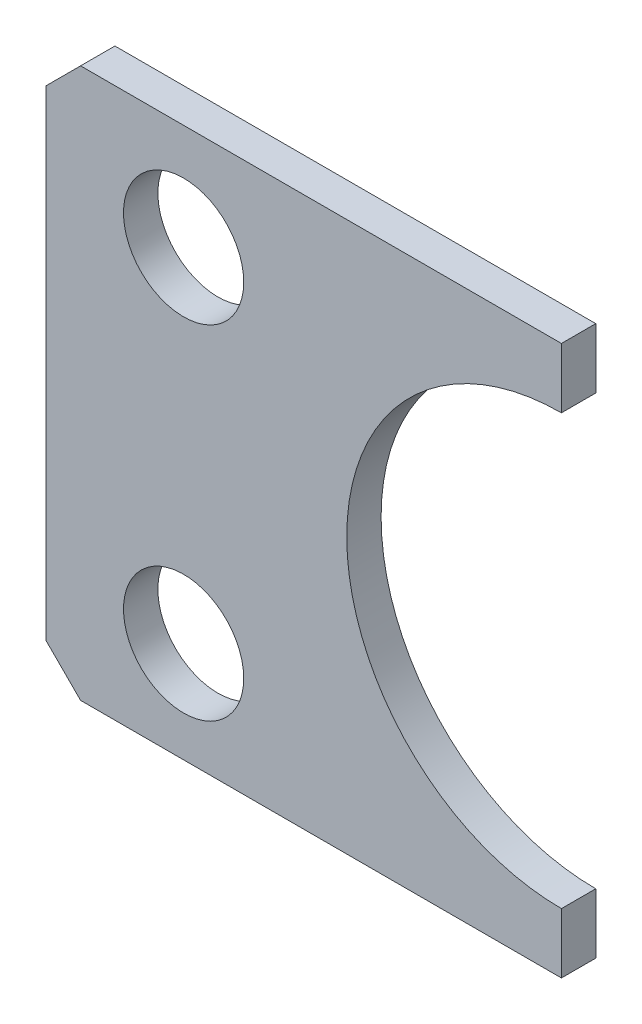
from build123d import *

# Parameters (mm, degrees)
SKETCH1_R           = 1.75
BOSS_EXTRUDE1_DEPTH = 1
CHAMFER1_SIZE       = 1


with BuildPart() as part:
    # Sketch1 → Boss-Extrude1 (new body)
    with BuildSketch(Plane.XY):
        with BuildLine():
            Line((7.5, -6.25), (7.5, -8))
            Line((7.5, -8), (-7.5, -8))
            Line((-7.5, -8), (-7.5, 8))
            Line((-7.5, 8), (7.5, 8))
            Line((7.5, 8), (7.5, 6.25))
            ThreePointArc((7.5, 6.25), (1.25, 0), (7.5, -6.25))
        make_face()
        with Locations((-3.5, 4.920147805)):
            Circle(SKETCH1_R, mode=Mode.SUBTRACT)
        with Locations((-3.5, -5.069977671)):
            Circle(SKETCH1_R, mode=Mode.SUBTRACT)
    extrude(amount=BOSS_EXTRUDE1_DEPTH)

    # Chamfer1
    chamfer1_edges = [part.edges().sort_by_distance(p)[0] for p in [
        (-7.5, -8, 0.5),
        (-7.5, 8, 0.5),
    ]]
    chamfer(chamfer1_edges, length=CHAMFER1_SIZE)


solid = part.part
